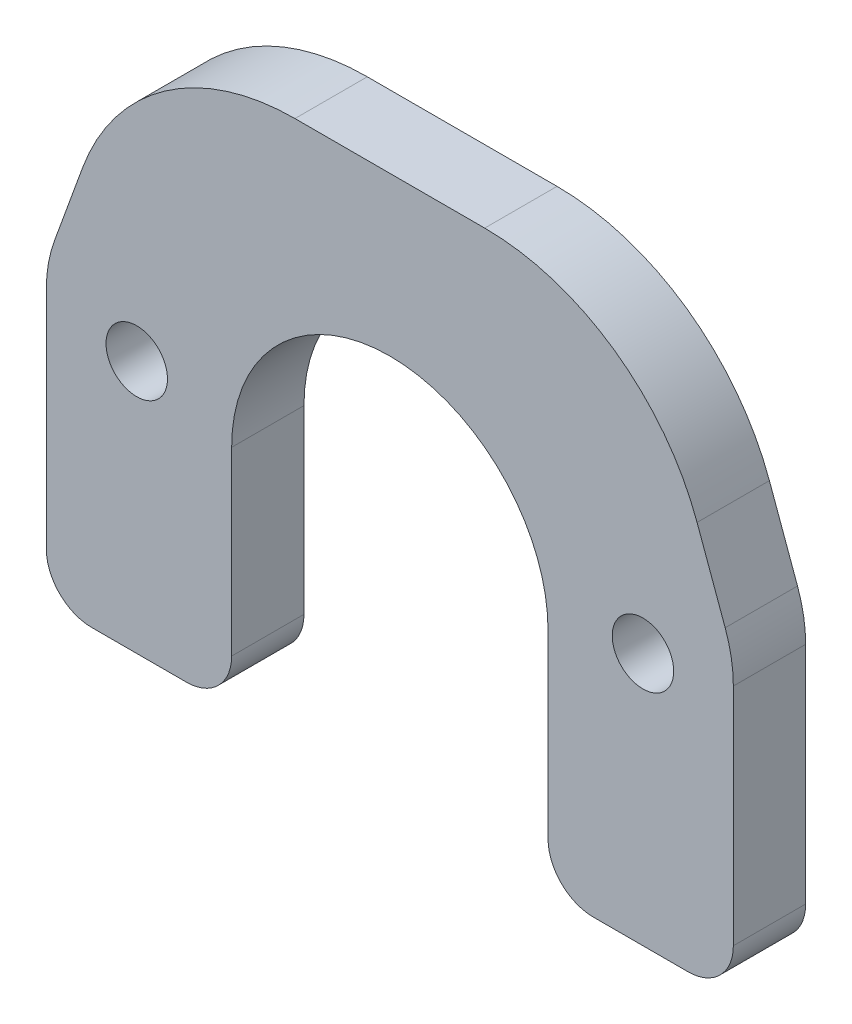
from build123d import *

# Parameters (mm, degrees)
BASE_EXTRUDE_DEPTH    = 8
SKETCH4_R             = 3.4
M8_GEVINDHULLER_DEPTH = 10


with BuildPart() as part:
    # Sketch1 → Base-Extrude (new body)
    with BuildSketch(Plane.XY):
        with BuildLine():
            Line((17.5, -17.5), (17.5, -37.5))
            ThreePointArc((17.5, -37.5), (18.964466094, -41.035533906), (22.5, -42.5))
            Line((22.5, -42.5), (33, -42.5))
            ThreePointArc((33, -42.5), (36.535533906, -41.035533906), (38, -37.5))
            Line((38, -37.5), (38, -12.619678905))
            ThreePointArc((38, -12.619678905), (37.772116295, -10.01495624), (37.095389312, -7.489376755))
            Line((37.095389312, -7.489376755), (33.987127064, 1.050503583))
            ThreePointArc((33.987127064, 1.050503583), (24.834222454, 12.978801107), (10.494811545, 17.5))
            Line((10.494811545, 17.5), (-10.494811545, 17.5))
            ThreePointArc((-10.494811545, 17.5), (-24.834222454, 12.978801107), (-33.987127064, 1.050503583))
            Line((-33.987127064, 1.050503583), (-37.095389312, -7.489376755))
            ThreePointArc((-37.095389312, -7.489376755), (-37.772116295, -10.01495624), (-38, -12.619678905))
            Line((-38, -12.619678905), (-38, -37.5))
            ThreePointArc((-38, -37.5), (-36.535533906, -41.035533906), (-33, -42.5))
            Line((-33, -42.5), (-22.5, -42.5))
            ThreePointArc((-22.5, -42.5), (-18.964466094, -41.035533906), (-17.5, -37.5))
            Line((-17.5, -37.5), (-17.5, -17.5))
            ThreePointArc((-17.5, -17.5), (0, 0), (17.5, -17.5))
        make_face()
    extrude(amount=BASE_EXTRUDE_DEPTH)

    # Sketch4 → M8 gevindhuller (cut)
    with BuildSketch(Plane.XY.offset(8)):
        with Locations((-28, -14.5)):
            Circle(SKETCH4_R)
        with Locations((28, -14.5)):
            Circle(SKETCH4_R)
    extrude(amount=-M8_GEVINDHULLER_DEPTH, mode=Mode.SUBTRACT)


solid = part.part
